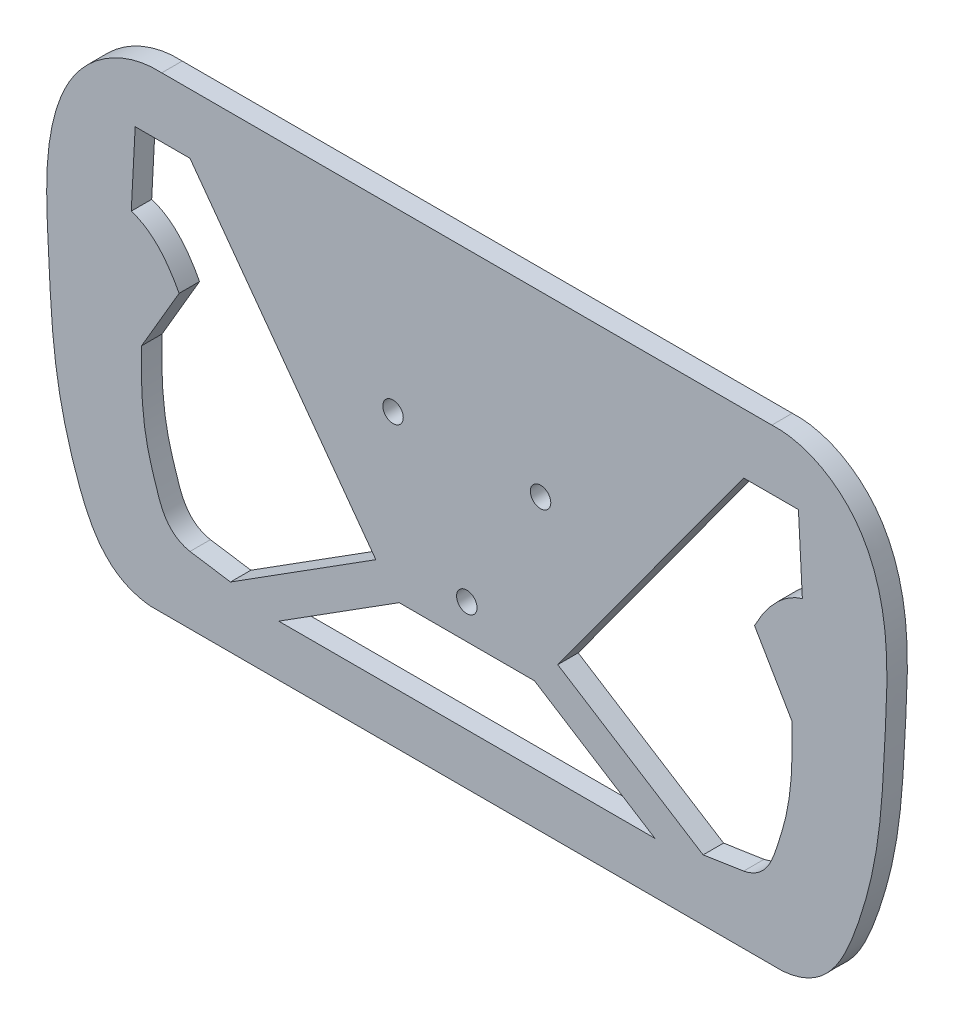
from build123d import *

# Parameters (mm, degrees)
SKETCH1_R           = 3
BOSS_EXTRUDE1_DEPTH = 6


with BuildPart() as part:
    # Sketch1 → Boss-Extrude1 (new body)
    with BuildSketch(Plane.XY):
        with BuildLine():
            Line((92.841871249, -72.503941705), (-92.841871249, -72.503941705))
            add(Edge.make_bspline(
                [(-89.54335041, 64.722361891), (-98.90871893, 65.221288052), (-113.81480539, 57.284527757), (-124.422620364, 32.021117456), (-122.771348874, 4.038133367), (-121.528600594, -25.817527247), (-114.338873962, -53.627324125), (-105.568117143, -71.312185373), (-92.841871249, -72.503941705)],
                knots=[0, 0, 0, 0, 0.167204326, 0.270778215, 0.47913381, 0.664790472, 0.809328273, 1, 1, 1, 1], degree=3))
            Line((-89.54335041, 64.722361891), (89.54335041, 64.722361891))
            add(Edge.make_bspline(
                [(89.54335041, 64.722361891), (98.90871893, 65.221288052), (113.81480539, 57.284527757), (124.422620364, 32.021117456), (122.771348874, 4.038133367), (121.528600594, -25.817527247), (114.338873962, -53.627324125), (105.568117143, -71.312185373), (92.841871249, -72.503941705)],
                knots=[0, 0, 0, 0, 0.167204326, 0.270778215, 0.47913381, 0.664790472, 0.809328273, 1, 1, 1, 1], degree=3))
        make_face()
        with Locations((-21.650635095, 12.5)):
            Circle(SKETCH1_R, mode=Mode.SUBTRACT)
        with Locations((21.650635095, 12.5)):
            Circle(SKETCH1_R, mode=Mode.SUBTRACT)
        with Locations((0, -25)):
            Circle(SKETCH1_R, mode=Mode.SUBTRACT)
        with BuildLine():
            Line((97.34394992, 47.131251227), (98.499872101, 25.079812686))
            add(Edge.make_bspline(
                [(98.499872101, 25.079812686), (91.893678399, 23.057749928), (87.513780679, 17.013291572), (84.45097174, 11.208746507)],
                knots=[0, 0, 0, 0, 1, 1, 1, 1], degree=3))
            Line((84.45097174, 11.208746507), (95.476691011, -7.641676762))
            add(Edge.make_bspline(
                [(95.476691011, -7.641676762), (95.652402082, -15.857734775), (95.502353613, -27.478143499), (90.619630404, -43.300604068), (87.814539084, -51.453126083), (81.260626519, -52.808002251)],
                knots=[0, 0, 0, 0, 0.501052944, 0.6781501, 1, 1, 1, 1], degree=3))
            Line((81.260626519, -52.808002251), (69.370032777, -54.628626567))
            Line((69.370032777, -54.628626567), (26.69421199, -27.617833137))
            Line((26.69421199, -27.617833137), (81.260626519, 47.131251227))
            Line((81.260626519, 47.131251227), (97.34394992, 47.131251227))
        make_face(mode=Mode.SUBTRACT)
        Polygon((-19.861614429, -35.127974027), (19.861614429, -35.127974027), (55.214622071, -57.503941705), (-55.214622071, -57.503941705), align=None, mode=Mode.SUBTRACT)
        with BuildLine():
            Line((-97.34394992, 47.131251227), (-81.260626519, 47.131251227))
            Line((-81.260626519, 47.131251227), (-26.69421199, -27.617833137))
            Line((-26.69421199, -27.617833137), (-69.370032777, -54.628626567))
            Line((-69.370032777, -54.628626567), (-81.260626519, -52.808002251))
            add(Edge.make_bspline(
                [(-95.476691011, -7.641676762), (-95.652402082, -15.857734775), (-95.502353613, -27.478143499), (-90.619630404, -43.300604068), (-87.814539084, -51.453126083), (-81.260626519, -52.808002251)],
                knots=[0, 0, 0, 0, 0.501052944, 0.6781501, 1, 1, 1, 1], degree=3))
            Line((-95.476691011, -7.641676762), (-84.45097174, 11.208746507))
            add(Edge.make_bspline(
                [(-98.499872101, 25.079812686), (-91.893678399, 23.057749928), (-87.513780679, 17.013291572), (-84.45097174, 11.208746507)],
                knots=[0, 0, 0, 0, 1, 1, 1, 1], degree=3))
            Line((-98.499872101, 25.079812686), (-97.34394992, 47.131251227))
        make_face(mode=Mode.SUBTRACT)
    extrude(amount=BOSS_EXTRUDE1_DEPTH)


solid = part.part
